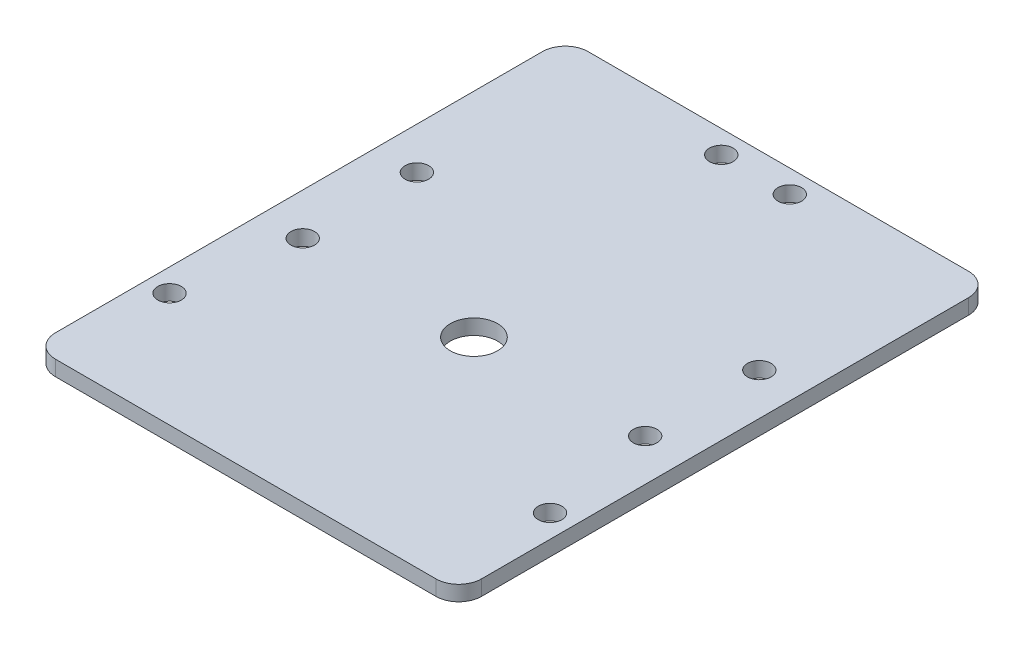
from build123d import *

# Parameters (mm, degrees)
SKETCH1_W           = 56
SKETCH1_H           = 70
SKETCH1_R           = 1.55
SKETCH1_R_2         = 3.1
BOSS_EXTRUDE1_DEPTH = 2
FILLET1_R           = 3


with BuildPart() as part:
    # Sketch1 → Boss-Extrude1 (new body)
    with BuildSketch(Plane(origin=(0, 0, 0), x_dir=(1, 0, 0), z_dir=(0, 1, 0))):
        Rectangle(SKETCH1_W, SKETCH1_H)
        with Locations((-22.5, -5)):
            Circle(SKETCH1_R, mode=Mode.SUBTRACT)
        with Locations((22.5, -5)):
            Circle(SKETCH1_R, mode=Mode.SUBTRACT)
        with Locations((-4.5, 32)):
            Circle(SKETCH1_R, mode=Mode.SUBTRACT)
        with Locations((4.5, 32)):
            Circle(SKETCH1_R, mode=Mode.SUBTRACT)
        with Locations((-22.5, 10)):
            Circle(SKETCH1_R, mode=Mode.SUBTRACT)
        with Locations((22.5, 10)):
            Circle(SKETCH1_R, mode=Mode.SUBTRACT)
        with Locations((-25, -20)):
            Circle(SKETCH1_R, mode=Mode.SUBTRACT)
        with Locations((25, -20)):
            Circle(SKETCH1_R, mode=Mode.SUBTRACT)
        with Locations((0, -5)):
            Circle(SKETCH1_R_2, mode=Mode.SUBTRACT)
    extrude(amount=BOSS_EXTRUDE1_DEPTH)

    # Fillet1
    fillet1_edges = [part.edges().sort_by_distance(p)[0] for p in [
        (28, 1, 35),
        (-28, 1, 35),
        (-28, 1, -35),
        (28, 1, -35),
    ]]
    fillet(fillet1_edges, radius=FILLET1_R)


solid = part.part
